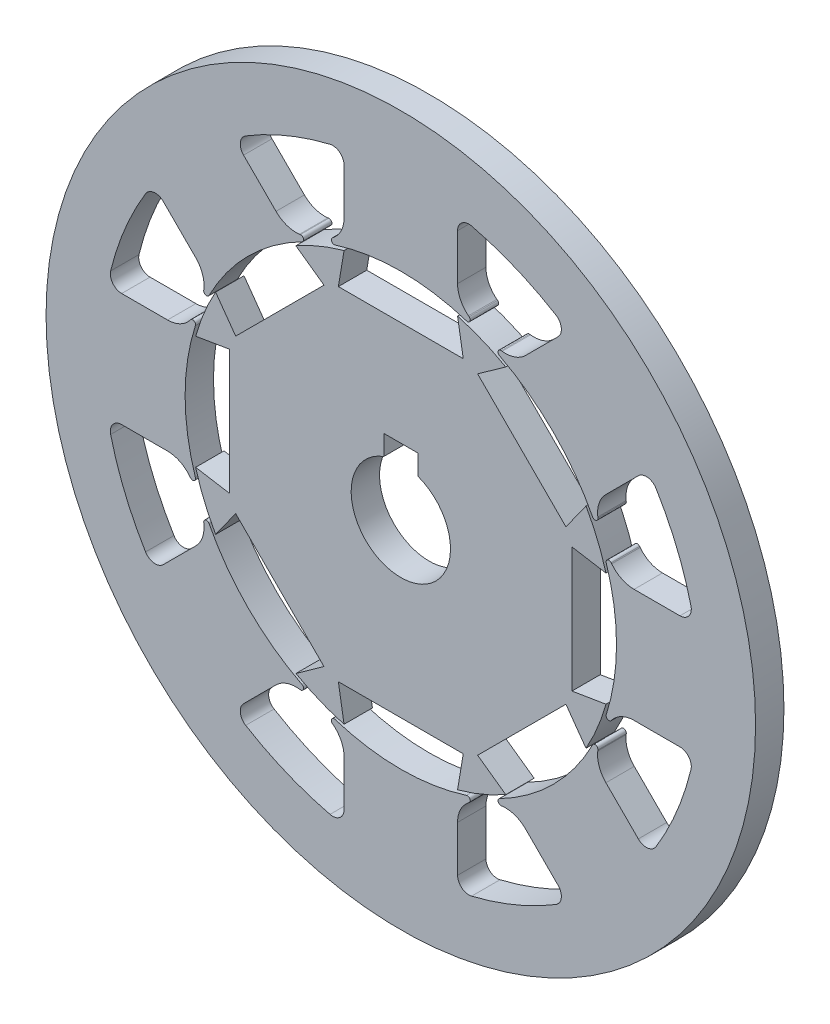
from build123d import *

# Parameters (mm, degrees)
IZIM1_R                       = 125
Y_KSEKLIK_EKSTR_ZYON1_DEPTH   = 10
Y_KSEKLIK_EKSTR_ZYON1_2_DEPTH = 10


with BuildPart() as part:
    # Çizim1 → Yükseklik-Ekstrüzyon1 (new body)
    with BuildSketch(Plane.XY):
        Circle(IZIM1_R)
        with BuildLine():
            Line((43.978252414, 72.262523662), (55.404106892, 83.68837814))
            ThreePointArc((55.404106892, 83.68837814), (56.547071865, 86.994345637), (54.65296685, 89.935120402))
            ThreePointArc((54.65296685, 89.935120402), (40.273268186, 97.228270255), (24.948250031, 102.239216974))
            ThreePointArc((24.948250031, 102.239216974), (21.529473753, 101.499109697), (20, 98.353239378))
            Line((20, 98.353239378), (20, 82.194641014))
            ThreePointArc((20, 82.194641014), (21.010680084, 77.813758973), (23.838425491, 74.318410978))
            Line((23.838425491, 74.318410978), (24.088437737, 74.122826407))
            ThreePointArc((24.088437737, 74.122826407), (24.356110031, 72.867394701), (23.167445477, 72.382798164))
            ThreePointArc((23.167445477, 72.382798164), (0, 76), (-23.167445477, 72.382798164))
            ThreePointArc((-23.167445477, 72.382798164), (-24.356110031, 72.867394701), (-24.088437737, 74.122826407))
            Line((-24.088437737, 74.122826407), (-23.838425491, 74.318410978))
            ThreePointArc((-23.838425491, 74.318410978), (-21.010680084, 77.813758973), (-20, 82.194641014))
            Line((-20, 82.194641014), (-20, 98.353239378))
            ThreePointArc((-20, 98.353239378), (-21.529473753, 101.499109697), (-24.948250031, 102.239216974))
            ThreePointArc((-24.948250031, 102.239216974), (-40.273268186, 97.228270255), (-54.65296685, 89.935120402))
            ThreePointArc((-54.65296685, 89.935120402), (-56.547071865, 86.994345637), (-55.404106892, 83.68837814))
            Line((-55.404106892, 83.68837814), (-43.978252414, 72.262523662))
            ThreePointArc((-43.978252414, 72.262523662), (-40.165842274, 69.879431005), (-35.694740052, 69.407364688))
            Line((-35.694740052, 69.407364688), (-35.379655521, 69.445850865))
            ThreePointArc((-35.379655521, 69.445850865), (-34.302658354, 68.747399486), (-34.800509624, 67.564225223))
            ThreePointArc((-34.800509624, 67.564225223), (-53.74011537, 53.74011537), (-67.564225223, 34.800509624))
            ThreePointArc((-67.564225223, 34.800509624), (-68.747399486, 34.302658354), (-69.445850865, 35.379655521))
            Line((-69.445850865, 35.379655521), (-69.407364688, 35.694740052))
            ThreePointArc((-69.407364688, 35.694740052), (-69.879431005, 40.165842274), (-72.262523662, 43.978252414))
            Line((-72.262523662, 43.978252414), (-83.68837814, 55.404106892))
            ThreePointArc((-83.68837814, 55.404106892), (-86.994345637, 56.547071865), (-89.935120402, 54.65296685))
            ThreePointArc((-89.935120402, 54.65296685), (-97.228270255, 40.273268186), (-102.239216974, 24.948250031))
            ThreePointArc((-102.239216974, 24.948250031), (-101.499109697, 21.529473753), (-98.353239378, 20))
            Line((-98.353239378, 20), (-82.194641014, 20))
            ThreePointArc((-82.194641014, 20), (-77.813758973, 21.010680084), (-74.318410978, 23.838425491))
            Line((-74.318410978, 23.838425491), (-74.122826407, 24.088437737))
            ThreePointArc((-74.122826407, 24.088437737), (-72.867394701, 24.356110031), (-72.382798164, 23.167445477))
            ThreePointArc((-72.382798164, 23.167445477), (-76, 0), (-72.382798164, -23.167445477))
            ThreePointArc((-72.382798164, -23.167445477), (-72.867394701, -24.356110031), (-74.122826407, -24.088437737))
            Line((-74.122826407, -24.088437737), (-74.318410978, -23.838425491))
            ThreePointArc((-74.318410978, -23.838425491), (-77.813758973, -21.010680084), (-82.194641014, -20))
            Line((-82.194641014, -20), (-98.353239378, -20))
            ThreePointArc((-98.353239378, -20), (-101.499109697, -21.529473753), (-102.239216974, -24.948250031))
            ThreePointArc((-102.239216974, -24.948250031), (-97.228270255, -40.273268186), (-89.935120402, -54.65296685))
            ThreePointArc((-89.935120402, -54.65296685), (-86.994345637, -56.547071865), (-83.68837814, -55.404106892))
            Line((-83.68837814, -55.404106892), (-72.262523662, -43.978252414))
            ThreePointArc((-72.262523662, -43.978252414), (-69.879431005, -40.165842274), (-69.407364688, -35.694740052))
            Line((-69.407364688, -35.694740052), (-69.445850865, -35.379655521))
            ThreePointArc((-69.445850865, -35.379655521), (-68.747399486, -34.302658354), (-67.564225223, -34.800509624))
            ThreePointArc((-67.564225223, -34.800509624), (-53.74011537, -53.74011537), (-34.800509624, -67.564225223))
            ThreePointArc((-34.800509624, -67.564225223), (-34.302658354, -68.747399486), (-35.379655521, -69.445850865))
            Line((-35.379655521, -69.445850865), (-35.694740052, -69.407364688))
            ThreePointArc((-35.694740052, -69.407364688), (-40.165842274, -69.879431005), (-43.978252414, -72.262523662))
            Line((-43.978252414, -72.262523662), (-55.404106892, -83.68837814))
            ThreePointArc((-55.404106892, -83.68837814), (-56.547071865, -86.994345637), (-54.65296685, -89.935120402))
            ThreePointArc((-54.65296685, -89.935120402), (-40.273268186, -97.228270255), (-24.948250031, -102.239216974))
            ThreePointArc((-24.948250031, -102.239216974), (-21.529473753, -101.499109697), (-20, -98.353239378))
            Line((-20, -98.353239378), (-20, -82.194641014))
            ThreePointArc((-20, -82.194641014), (-21.010680084, -77.813758973), (-23.838425491, -74.318410978))
            Line((-23.838425491, -74.318410978), (-24.088437737, -74.122826407))
            ThreePointArc((-24.088437737, -74.122826407), (-24.356110031, -72.867394701), (-23.167445477, -72.382798164))
            ThreePointArc((-23.167445477, -72.382798164), (0, -76), (23.167445477, -72.382798164))
            ThreePointArc((23.167445477, -72.382798164), (24.356110031, -72.867394701), (24.088437737, -74.122826407))
            Line((24.088437737, -74.122826407), (23.838425491, -74.318410978))
            ThreePointArc((23.838425491, -74.318410978), (21.010680084, -77.813758973), (20, -82.194641014))
            Line((20, -82.194641014), (20, -98.353239378))
            ThreePointArc((20, -98.353239378), (21.529473753, -101.499109697), (24.948250031, -102.239216974))
            ThreePointArc((24.948250031, -102.239216974), (40.273268186, -97.228270255), (54.65296685, -89.935120402))
            ThreePointArc((54.65296685, -89.935120402), (56.547071865, -86.994345637), (55.404106892, -83.68837814))
            Line((55.404106892, -83.68837814), (43.978252414, -72.262523662))
            ThreePointArc((43.978252414, -72.262523662), (40.165842274, -69.879431005), (35.694740052, -69.407364688))
            Line((35.694740052, -69.407364688), (35.379655521, -69.445850865))
            ThreePointArc((35.379655521, -69.445850865), (34.302658354, -68.747399486), (34.800509624, -67.564225223))
            ThreePointArc((34.800509624, -67.564225223), (53.74011537, -53.74011537), (67.564225223, -34.800509624))
            ThreePointArc((67.564225223, -34.800509624), (68.747399486, -34.302658354), (69.445850865, -35.379655521))
            Line((69.445850865, -35.379655521), (69.407364688, -35.694740052))
            ThreePointArc((69.407364688, -35.694740052), (69.879431005, -40.165842274), (72.262523662, -43.978252414))
            Line((72.262523662, -43.978252414), (83.68837814, -55.404106892))
            ThreePointArc((83.68837814, -55.404106892), (86.994345637, -56.547071865), (89.935120402, -54.65296685))
            ThreePointArc((89.935120402, -54.65296685), (97.228270255, -40.273268186), (102.239216974, -24.948250031))
            ThreePointArc((102.239216974, -24.948250031), (101.499109697, -21.529473753), (98.353239378, -20))
            Line((98.353239378, -20), (82.194641014, -20))
            ThreePointArc((82.194641014, -20), (77.813758973, -21.010680084), (74.318410978, -23.838425491))
            Line((74.318410978, -23.838425491), (74.122826407, -24.088437737))
            ThreePointArc((74.122826407, -24.088437737), (72.867394701, -24.356110031), (72.382798164, -23.167445477))
            ThreePointArc((72.382798164, -23.167445477), (76, 0), (72.382798164, 23.167445477))
            ThreePointArc((72.382798164, 23.167445477), (72.867394701, 24.356110031), (74.122826407, 24.088437737))
            Line((74.122826407, 24.088437737), (74.318410978, 23.838425491))
            ThreePointArc((74.318410978, 23.838425491), (77.813758973, 21.010680084), (82.194641014, 20))
            Line((82.194641014, 20), (98.353239378, 20))
            ThreePointArc((98.353239378, 20), (101.499109697, 21.529473753), (102.239216974, 24.948250031))
            ThreePointArc((102.239216974, 24.948250031), (97.228270255, 40.273268186), (89.935120402, 54.65296685))
            ThreePointArc((89.935120402, 54.65296685), (86.994345637, 56.547071865), (83.68837814, 55.404106892))
            Line((83.68837814, 55.404106892), (72.262523662, 43.978252414))
            ThreePointArc((72.262523662, 43.978252414), (69.879431005, 40.165842274), (69.407364688, 35.694740052))
            Line((69.407364688, 35.694740052), (69.445850865, 35.379655521))
            ThreePointArc((69.445850865, 35.379655521), (68.747399486, 34.302658354), (67.564225223, 34.800509624))
            ThreePointArc((67.564225223, 34.800509624), (53.74011537, 53.74011537), (34.800509624, 67.564225223))
            ThreePointArc((34.800509624, 67.564225223), (34.302658354, 68.747399486), (35.379655521, 69.445850865))
            Line((35.379655521, 69.445850865), (35.694740052, 69.407364688))
            ThreePointArc((35.694740052, 69.407364688), (40.165842274, 69.879431005), (43.978252414, 72.262523662))
        make_face(mode=Mode.SUBTRACT)
    extrude(amount=Y_KSEKLIK_EKSTR_ZYON1_DEPTH)


with BuildPart() as body_2:
    # Çizim1 → Y_kseklik-Ekstr_zyon1 2 (new body)
    with BuildSketch(Plane.XY):
        with BuildLine():
            Line((-20, 72.284161474), (-22, 60.284161474))
            Line((-22, 60.284161474), (22, 60.284161474))
            Line((22, 60.284161474), (20, 72.284161474))
            ThreePointArc((20, 72.284161474), (28.701257427, 69.290964938), (36.970485127, 65.254756374))
            Line((36.970485127, 65.254756374), (27.07099019, 58.183688563))
            Line((27.07099019, 58.183688563), (58.183688563, 27.07099019))
            Line((58.183688563, 27.07099019), (65.254756374, 36.970485127))
            ThreePointArc((65.254756374, 36.970485127), (69.290964938, 28.701257427), (72.284161474, 20))
            Line((72.284161474, 20), (60.284161474, 22))
            Line((60.284161474, 22), (60.284161474, -22))
            Line((60.284161474, -22), (72.284161474, -20))
            ThreePointArc((72.284161474, -20), (69.290964938, -28.701257427), (65.254756374, -36.970485127))
            Line((65.254756374, -36.970485127), (58.183688563, -27.07099019))
            Line((58.183688563, -27.07099019), (27.07099019, -58.183688563))
            Line((27.07099019, -58.183688563), (36.970485127, -65.254756374))
            ThreePointArc((36.970485127, -65.254756374), (28.701257427, -69.290964938), (20, -72.284161474))
            Line((20, -72.284161474), (22, -60.284161474))
            Line((22, -60.284161474), (-22, -60.284161474))
            Line((-22, -60.284161474), (-20, -72.284161474))
            ThreePointArc((-20, -72.284161474), (-28.701257427, -69.290964938), (-36.970485127, -65.254756374))
            Line((-36.970485127, -65.254756374), (-27.07099019, -58.183688563))
            Line((-27.07099019, -58.183688563), (-58.183688563, -27.07099019))
            Line((-58.183688563, -27.07099019), (-65.254756374, -36.970485127))
            ThreePointArc((-65.254756374, -36.970485127), (-69.290964938, -28.701257427), (-72.284161474, -20))
            Line((-72.284161474, -20), (-60.284161474, -22))
            Line((-60.284161474, -22), (-60.284161474, 22))
            Line((-60.284161474, 22), (-72.284161474, 20))
            ThreePointArc((-72.284161474, 20), (-69.290964938, 28.701257427), (-65.254756374, 36.970485127))
            Line((-65.254756374, 36.970485127), (-58.183688563, 27.07099019))
            Line((-58.183688563, 27.07099019), (-27.07099019, 58.183688563))
            Line((-27.07099019, 58.183688563), (-36.970485127, 65.254756374))
            ThreePointArc((-36.970485127, 65.254756374), (-28.701257427, 69.290964938), (-20, 72.284161474))
        make_face()
        with BuildLine():
            Line((-6, 23.5), (6, 23.5))
            Line((6, 23.5), (6, 16.439282223))
            ThreePointArc((6, 16.439282223), (0, -17.5), (-6, 16.439282223))
            Line((-6, 16.439282223), (-6, 23.5))
        make_face(mode=Mode.SUBTRACT)
    extrude(amount=Y_KSEKLIK_EKSTR_ZYON1_2_DEPTH)


solid = Compound([part.part, body_2.part])
